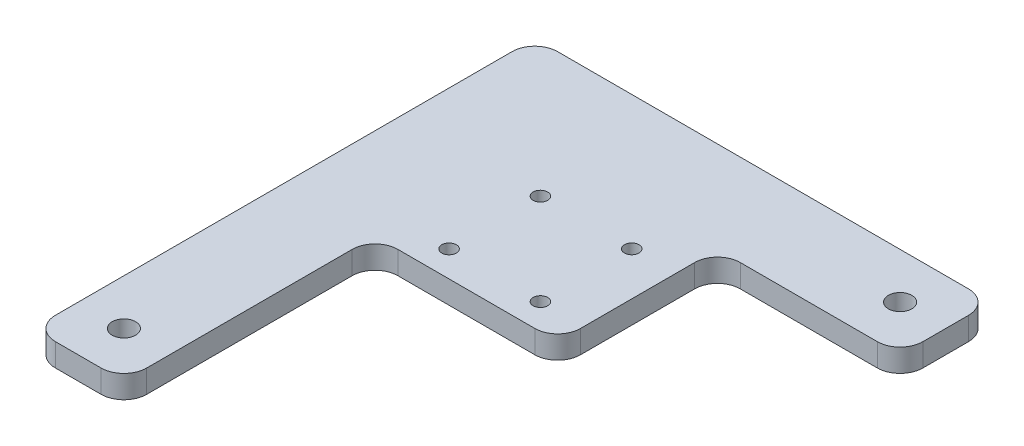
from build123d import *

# Parameters (mm, degrees)
SKETCH1_R                   = 3.2639
BOSS_EXTRUDE1_DEPTH         = 6.35
FILLET1_R                   = 6.35
FILLET4_R                   = 6.35
FILLET5_R                   = 6.35
FILLET6_R                   = 6.35
FILLET9_R                   = 6.35
FILLET10_R                  = 6.35
FILLET11_R                  = 6.35
FILLET12_R                  = 6.35
F_21_0_159_DIAMETER_HOLE1_D = 4.0386


with BuildPart() as part:
    # Sketch1 → Boss-Extrude1 (new body)
    with BuildSketch(Plane(origin=(0, 0, 0), x_dir=(1, 0, 0), z_dir=(0, 1, 0))):
        Polygon((-53.941595929, 54.013787086), (73.058404071, 54.013787086), (73.058404071, 28.613787086), (22.258404071, 28.613787086), (22.258404071, -15.836212914), (-28.541595929, -15.836212914), (-28.541595929, -85.686212914), (-53.941595929, -85.686212914), align=None)
        with Locations((-41.241595929, -72.986212914)):
            Circle(SKETCH1_R, mode=Mode.SUBTRACT)
        with Locations((60.358404071, 41.313787086)):
            Circle(SKETCH1_R, mode=Mode.SUBTRACT)
    extrude(amount=BOSS_EXTRUDE1_DEPTH)

    # Fillet1
    fillet1_edges = [part.edges().sort_by_distance(p)[0] for p in [
        (-28.541595929, 3.175, 15.836212914),
    ]]
    fillet(fillet1_edges, radius=FILLET1_R)

    # Fillet4
    fillet4_edges = [part.edges().sort_by_distance(p)[0] for p in [
        (-53.941595929, 3.175, -54.013787086),
    ]]
    fillet(fillet4_edges, radius=FILLET4_R)

    # Fillet5
    fillet5_edges = [part.edges().sort_by_distance(p)[0] for p in [
        (-53.941595929, 3.175, 85.686212914),
    ]]
    fillet(fillet5_edges, radius=FILLET5_R)

    # Fillet6
    fillet6_edges = [part.edges().sort_by_distance(p)[0] for p in [
        (-28.541595929, 3.175, 85.686212914),
    ]]
    fillet(fillet6_edges, radius=FILLET6_R)

    # Fillet9
    fillet9_edges = [part.edges().sort_by_distance(p)[0] for p in [
        (22.258404071, 3.175, 15.836212914),
    ]]
    fillet(fillet9_edges, radius=FILLET9_R)

    # Fillet10
    fillet10_edges = [part.edges().sort_by_distance(p)[0] for p in [
        (22.258404071, 3.175, -28.613787086),
    ]]
    fillet(fillet10_edges, radius=FILLET10_R)

    # Fillet11
    fillet11_edges = [part.edges().sort_by_distance(p)[0] for p in [
        (73.058404071, 3.175, -28.613787086),
    ]]
    fillet(fillet11_edges, radius=FILLET11_R)

    # Fillet12
    fillet12_edges = [part.edges().sort_by_distance(p)[0] for p in [
        (73.058404071, 3.175, -54.013787086),
    ]]
    fillet(fillet12_edges, radius=FILLET12_R)

    # #21 (0.159) Diameter Hole1 (through all)
    with Locations(Plane(origin=(0, 6.35, 0), x_dir=(1, 0, 0), z_dir=(0, 1, 0))):
        with Locations((-15.182373473, 16.802787086), (-15.182373473, -8.597212914), (10.217626527, -8.597212914), (10.217626527, 16.802787086)):
            Hole(F_21_0_159_DIAMETER_HOLE1_D / 2)


solid = part.part
